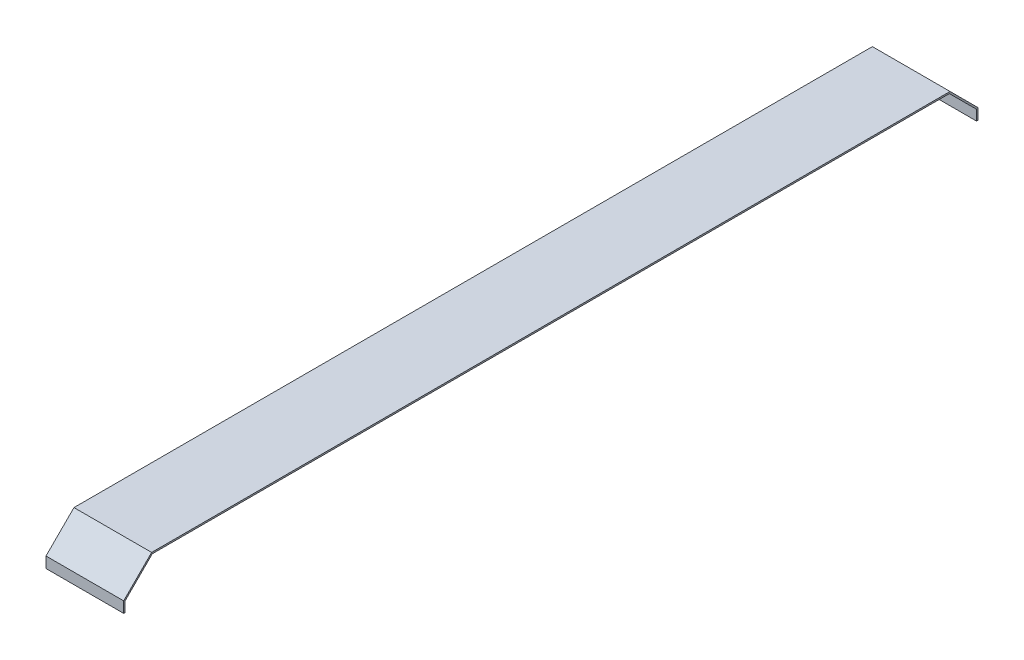
from build123d import *

# Parameters (mm, degrees)
EXTRUDE_1_DEPTH = 50


with BuildPart() as part:
    # 草图1 → 凸台-拉伸1 (new body)
    with BuildSketch(Plane(origin=(0, 0, 0), x_dir=(0, 0, -1), z_dir=(1, 0, 0))):
        Polygon((-257, 0), (257, 0), (275, -18), (275, -25), (274, -25), (274, -18.414213562), (256.585786438, -1), (-256.585786438, -1), (-274, -18.414213562), (-274, -25), (-275, -25), (-275, -18), align=None)
    extrude(amount=EXTRUDE_1_DEPTH)


solid = part.part
